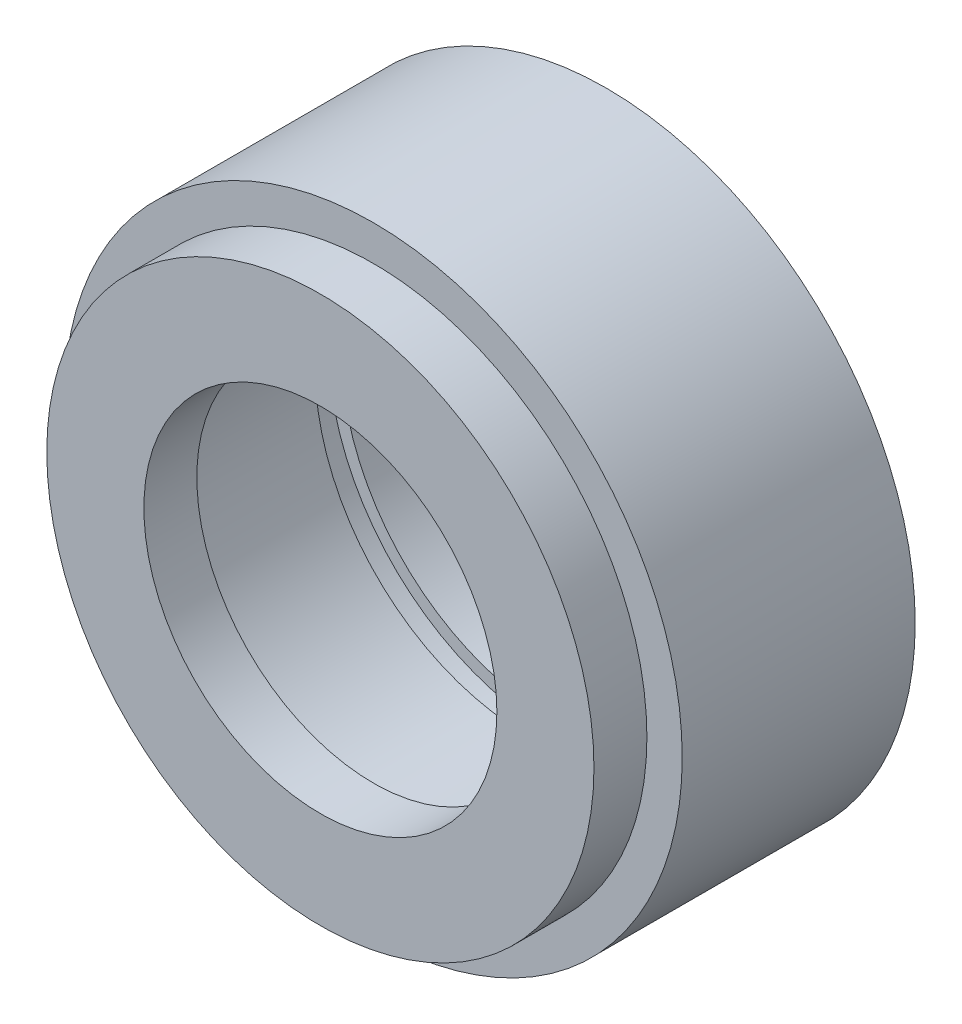
from build123d import *


with BuildPart() as part:
    # Эскиз1 → Повернуть1 (revolve)
    with BuildSketch(Plane(origin=(0, 0, 0), x_dir=(0, 0, -1), z_dir=(1, 0, 0))):
        Polygon((-9, 12), (-9, 10), (-12, 10), (-12, 15.5), (-9, 15.5), (-9, 17.5), (4.2, 17.5), (4.2, 12), (1.2, 12), (1.2, 12.75), (-0.3, 12.75), (-0.3, 12), align=None)
    revolve(axis=Axis((0, 0, 1000), (0, 0, -1)))


solid = part.part
